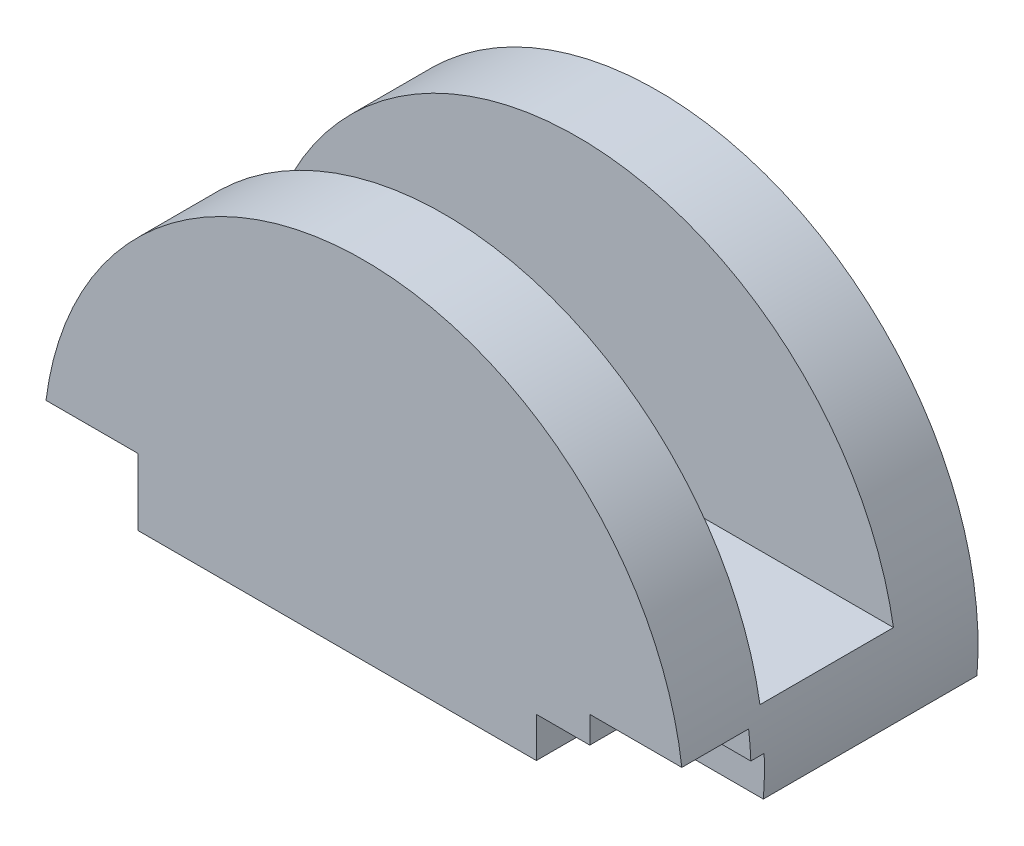
from build123d import *

# Parameters (mm, degrees)
BOSS_EXTRUDE1_DEPTH     = 11
CUT_EXTRUDE1_START      = 3
SKETCH2_R               = 4.25
CUT_EXTRUDE1_DEPTH      = 4
SKETCH3_W               = 5
SKETCH3_H               = 13.464597237
CUT_EXTRUDE2_DEPTH      = 13
CUT_EXTRUDE2_DEPTH_BACK = 13
SKETCH4_W               = 7.273345506
SKETCH4_H               = 1.5
CUT_EXTRUDE3_DEPTH      = 3
SKETCH5_W               = 4.264362618
SKETCH5_H               = 2.5
CUT_EXTRUDE4_DEPTH      = 2.5
SKETCH6_W               = 5.237267166
SKETCH6_H               = 2.5
CUT_EXTRUDE5_DEPTH      = 2.5


with BuildPart() as part:
    # Sketch1 → Boss-Extrude1 (new body)
    with BuildSketch(Plane.XY):
        with BuildLine():
            Line((-11.958260743, -1), (11.958260743, -1))
            ThreePointArc((11.958260743, -1), (0, 12), (-11.958260743, -1))
        make_face()
    extrude(amount=BOSS_EXTRUDE1_DEPTH)

    # Sketch2 → Cut-Extrude1 (cut)
    with BuildSketch(Plane.XZ.offset(-2).offset(CUT_EXTRUDE1_START)):
        with Locations((0, 5.5)):
            Circle(SKETCH2_R)
    extrude(amount=-CUT_EXTRUDE1_DEPTH, mode=Mode.SUBTRACT)

    # Sketch3 → Cut-Extrude2 (cut, two sides)
    with BuildSketch(Plane(origin=(0, 0, 0), x_dir=(0, 0, -1), z_dir=(1, 0, 0))) as cut_extrude2_sk:
        with Locations((-5.5, 8.732298618)):
            Rectangle(SKETCH3_W, SKETCH3_H)
    extrude(amount=CUT_EXTRUDE2_DEPTH, mode=Mode.SUBTRACT)
    extrude(cut_extrude2_sk.sketch, amount=-CUT_EXTRUDE2_DEPTH_BACK, mode=Mode.SUBTRACT)

    # Sketch4 → Cut-Extrude3 (cut)
    with BuildSketch(Plane.XY.offset(11)):
        with Locations((10.094933496, -0.25)):
            Rectangle(SKETCH4_W, SKETCH4_H)
    extrude(amount=-CUT_EXTRUDE3_DEPTH, mode=Mode.SUBTRACT)

    # Sketch5 → Cut-Extrude4 (cut)
    with BuildSketch(Plane.XY.offset(11)):
        with Locations((-10.590442052, 0.25)):
            Rectangle(SKETCH5_W, SKETCH5_H)
    extrude(amount=-CUT_EXTRUDE4_DEPTH, mode=Mode.SUBTRACT)

    # Sketch6 → Cut-Extrude5 (cut)
    with BuildSketch(Plane.XY.offset(11)):
        with Locations((11.076894326, 0.25)):
            Rectangle(SKETCH6_W, SKETCH6_H)
    extrude(amount=-CUT_EXTRUDE5_DEPTH, mode=Mode.SUBTRACT)


solid = part.part
